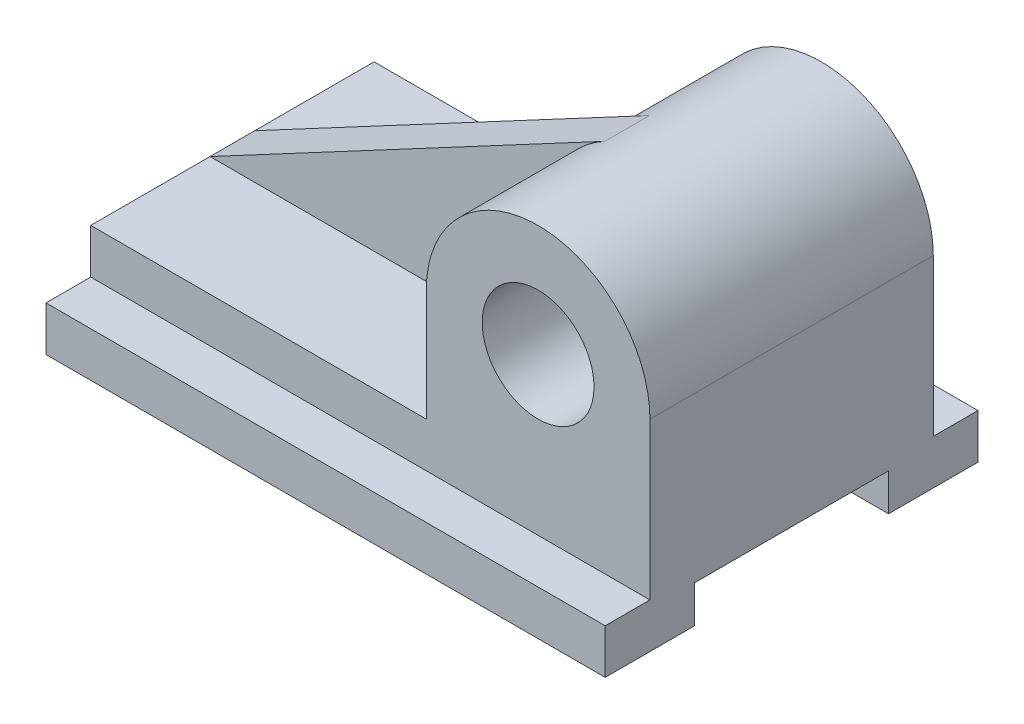
from build123d import *

# Parameters (mm, degrees)
SKETCH2_W           = 90
SKETCH2_H           = 24
BOSS_EXTRUDE1_DEPTH = 76
SKETCH3_W           = 150
SKETCH3_H           = 12
BOSS_EXTRUDE2_DEPTH = 12
SKETCH4_W           = 150
SKETCH4_H           = 12
BOSS_EXTRUDE3_DEPTH = 12
SKETCH5_W           = 150
SKETCH5_H           = 52
CUT_EXTRUDE1_DEPTH  = 10
BOSS_EXTRUDE6_DEPTH = 44
CUT_EXTRUDE2_DEPTH  = 32


with BuildPart() as part:
    # Sketch2 → Boss-Extrude1 (new body)
    with BuildSketch(Plane.XY):
        with BuildLine():
            Line((30, -54), (30, 0))
            ThreePointArc((30, 0), (0, -30), (-30, 0))
            Line((-30, 0), (-30, -30))
            Line((-30, -30), (-30, -54))
            Line((-30, -54), (30, -54))
        make_face()
        with Locations((-75, -42)):
            Rectangle(SKETCH2_W, SKETCH2_H)
        with BuildLine():
            ThreePointArc((-15, 0), (0, 15), (15, 0))
            Line((15, 0), (30, 0))
            ThreePointArc((30, 0), (0, 30), (-30, 0))
            Line((-30, 0), (-15, 0))
        make_face()
        with BuildLine():
            Line((30, 0), (15, 0))
            ThreePointArc((15, 0), (0, -15), (-15, 0))
            Line((-15, 0), (-30, 0))
            ThreePointArc((-30, 0), (0, -30), (30, 0))
        make_face()
    extrude(amount=BOSS_EXTRUDE1_DEPTH)

    # Sketch3 → Boss-Extrude2 (add)
    with BuildSketch(Plane.XY.offset(76)):
        with Locations((-45, -48)):
            Rectangle(SKETCH3_W, SKETCH3_H)
    extrude(amount=BOSS_EXTRUDE2_DEPTH)

    # Sketch4 → Boss-Extrude3 (add)
    with BuildSketch(Plane(origin=(0, 0, 0), x_dir=(-1, 0, 0), z_dir=(0, 0, -1))):
        with Locations((45, -48)):
            Rectangle(SKETCH4_W, SKETCH4_H)
    extrude(amount=BOSS_EXTRUDE3_DEPTH)

    # Sketch5 → Cut-Extrude1 (cut)
    with BuildSketch(Plane(origin=(0, -54, 0), x_dir=(-1, 0, 0), z_dir=(0, -1, 0))):
        with Locations((45, -38)):
            Rectangle(SKETCH5_W, SKETCH5_H)
    extrude(amount=-CUT_EXTRUDE1_DEPTH, mode=Mode.SUBTRACT)

    # Sketch11 → Boss-Extrude6 (add)
    with BuildSketch(Plane.XY):
        with BuildLine():
            Line((-14.117647059, 26.470588235), (-120, -30))
            Line((-120, -30), (-30, -30))
            Line((-30, -30), (-30, 0))
            ThreePointArc((-30, 0), (-25.724787771, 15.434872663), (-14.117647059, 26.470588235))
        make_face()
    extrude(amount=BOSS_EXTRUDE6_DEPTH)

    # Sketch13 → Cut-Extrude2 (cut)
    with BuildSketch(Plane.XY):
        with BuildLine():
            Line((-30, -30), (-30, 0))
            ThreePointArc((-30, 0), (-25.724787771, 15.434872663), (-14.117647059, 26.470588235))
            Line((-14.117647059, 26.470588235), (-120, -30))
            Line((-120, -30), (-30, -30))
        make_face()
    extrude(amount=CUT_EXTRUDE2_DEPTH, mode=Mode.SUBTRACT)


solid = part.part
